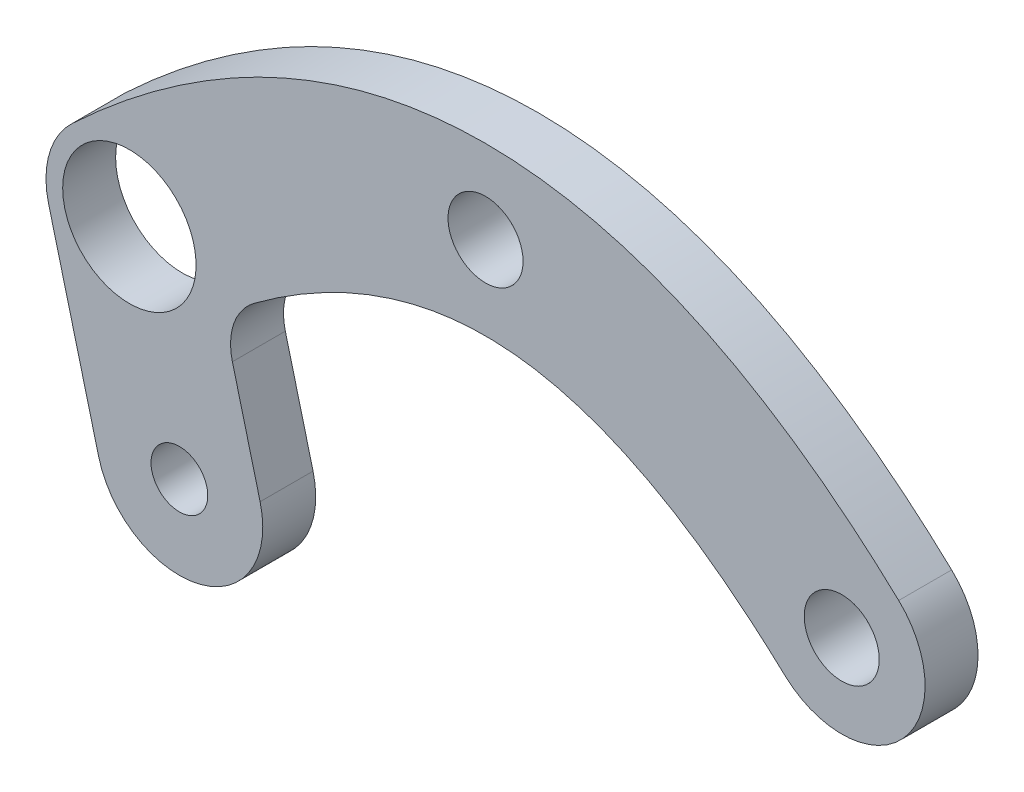
from build123d import *

# Parameters (mm, degrees)
BOSS_EXTRUDE1_DEPTH  = 1.5875
M4_CLEARANCE_HOLE1_D = 4.5
BOSS_EXTRUDE2_DEPTH  = 3.175
FILLET1_R            = 3.5
M3_CLEARANCE_HOLE1_D = 3.4
SKETCH8_R            = 4
CUT_EXTRUDE1_DEPTH   = 4.1750001


with BuildPart() as part:
    # Sketch2 → Boss-Extrude1 (new body, symmetric)
    with BuildSketch(Plane.XY):
        with BuildLine():
            ThreePointArc((-17.942568571, -13.649816766), (-25.009816766, -13.417431429), (-24.777431429, -6.350183234))
            add(Edge.make_bspline(
                [(-24.777431429, -6.350183234), (-20.441430485, -2.271315687), (-12.829947979, 2.196277878), (-6.501150321, 4.42663028), (0, 5.19112324), (6.501150321, 4.42663028), (12.829947979, 2.196277878), (20.441430485, -2.271315687), (24.777431429, -6.350183234)],
                knots=[0, 0, 0, 0.1875, 0.3125, 0.4375, 0.5625, 0.6875, 0.8125, 1, 1, 1], degree=2))
            ThreePointArc((24.777431429, -6.350183234), (25.009816766, -13.417431429), (17.942568571, -13.649816766))
            add(Edge.make_bspline(
                [(-17.942568571, -13.649816766), (-14.268569515, -10.228684313), (-8.530052021, -6.883777878), (-4.178849679, -5.36413028), (0, -4.87862324), (4.178849679, -5.36413028), (8.530052021, -6.883777878), (14.268569515, -10.228684313), (17.942568571, -13.649816766)],
                knots=[0, 0, 0, 0.1875, 0.3125, 0.4375, 0.5625, 0.6875, 0.8125, 1, 1, 1], degree=2))
        make_face()
    extrude(amount=BOSS_EXTRUDE1_DEPTH, both=True)

    # M4 Clearance Hole1 (through all)
    with Locations(Plane.XY.offset(1.5875)):
        with Locations((21.36, -10), (0, 0)):
            Hole(M4_CLEARANCE_HOLE1_D / 2)

    # Sketch5 → Boss-Extrude2 (add)
    with BuildSketch(Plane(origin=(0, 0, -1.5875), x_dir=(-1, 0, 0), z_dir=(0, 0, -1))):
        with BuildLine():
            ThreePointArc((13.518770817, -20.368950039), (17.11, -26.460179221), (23.201229183, -22.868950039))
            Line((23.201229183, -22.868950039), (26.201229183, -11.25))
            ThreePointArc((26.201229183, -11.25), (22.61, -5.158770817), (16.518770817, -8.75))
            Line((16.518770817, -8.75), (13.518770817, -20.368950039))
        make_face()
    extrude(amount=-BOSS_EXTRUDE2_DEPTH)

    # Fillet1
    fillet1_edges = [part.edges().sort_by_distance(p)[0] for p in [
        (-15.752223744, -11.718824048, 0.7937488),
    ]]
    fillet(fillet1_edges, radius=FILLET1_R)

    # M3 Clearance Hole1 (through all)
    with Locations(Plane(origin=(0, 0, -1.5875), x_dir=(-1, 0, 0), z_dir=(0, 0, -1))):
        with Locations((18.36, -21.618950039)):
            Hole(M3_CLEARANCE_HOLE1_D / 2)

    # Sketch8 → Cut-Extrude1 (cut, through all)
    with BuildSketch(Plane(origin=(0, 0, -1.5875), x_dir=(-1, 0, 0), z_dir=(0, 0, -1))):
        with Locations((21.36, -10)):
            Circle(SKETCH8_R)
    extrude(amount=-CUT_EXTRUDE1_DEPTH, mode=Mode.SUBTRACT)


solid = part.part
